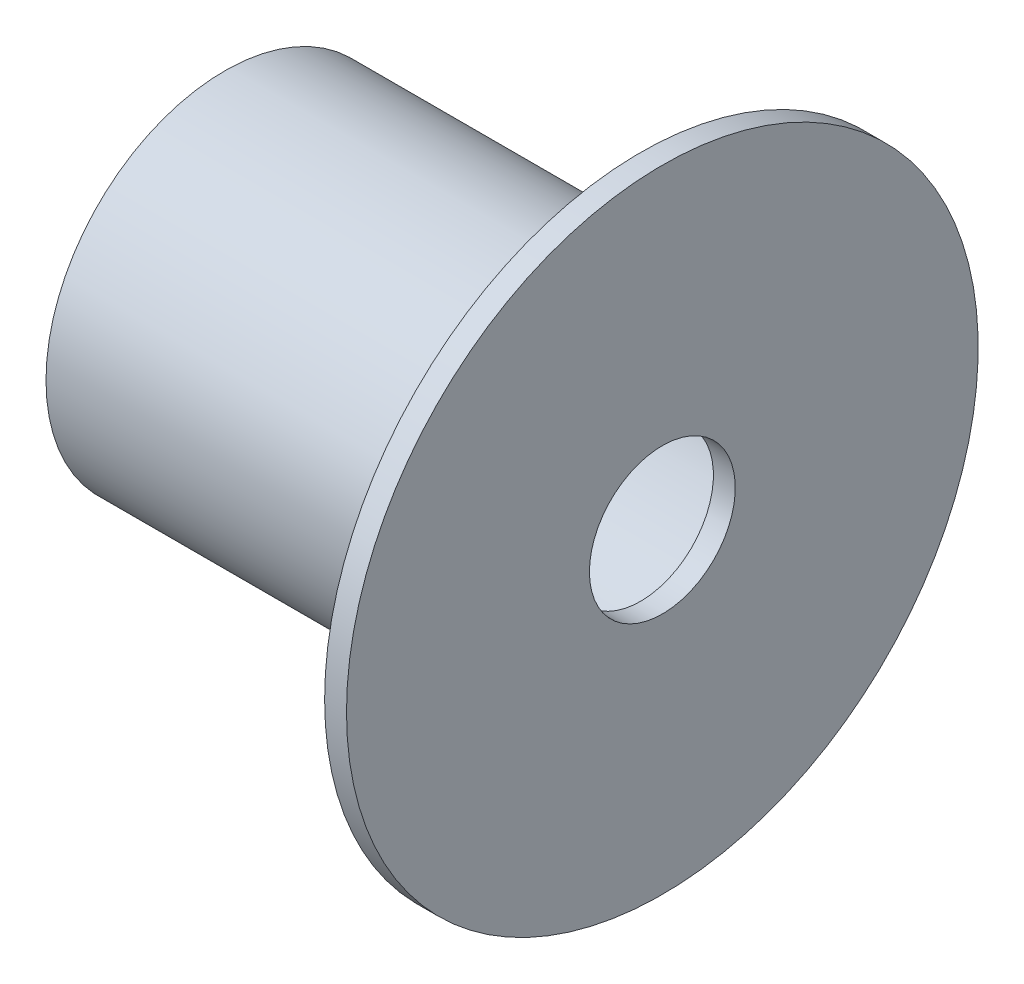
from build123d import *


with BuildPart() as part:
    # Sketch1 → Revolve1 (revolve)
    with BuildSketch(Plane.XY):
        Polygon((25.408906872, 7.906172878), (28.408906872, 7.906172878), (28.408906872, 41.213420622), (25.408906872, 41.213420622), (25.408906872, 22.413958281), (-31.591093128, 22.413958281), (-31.591093128, 20.413958281), (25.408906872, 20.413958281), align=None)
    revolve(axis=Axis((-17.762687395, -2.093827122, 0), (1, 0, 0)))


solid = part.part
